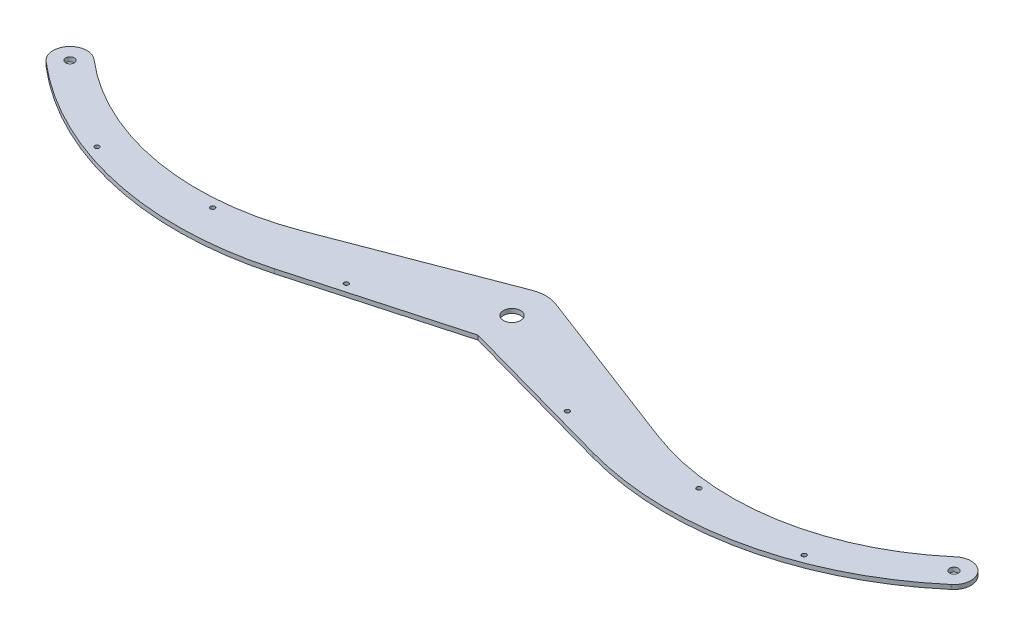
from build123d import *

# Parameters (mm, degrees)
BOSS_EXTRUDE1_DEPTH = 3.18
SKETCH3_R           = 3.175
SKETCH3_R_2         = 6.35
SKETCH3_R_3         = 1.65
CUT_EXTRUDE1_DEPTH  = 4.18


with BuildPart() as part:
    # Sketch1 → Boss-Extrude1 (new body)
    with BuildSketch(Plane(origin=(0, 0, 0), x_dir=(1, 0, 0), z_dir=(0, 1, 0))):
        with BuildLine():
            Line((-316.883271773, 9.506246519), (-316.457354569, 9.142585196))
            ThreePointArc((-316.457354569, 9.142585196), (-227.815789201, -32.465901654), (-130.352994696, -23.000333716))
            Line((-130.352994696, -23.000333716), (-8.915781366, 23.356130729))
            ThreePointArc((-8.915781366, 23.356130729), (0, 25), (8.915781366, 23.356130729))
            Line((8.915781366, 23.356130729), (130.352994696, -23.000333716))
            ThreePointArc((130.352994696, -23.000333716), (227.815789201, -32.465901654), (316.457354569, 9.142585196))
            Line((316.457354569, 9.142585196), (316.883271773, 9.506246519))
            ThreePointArc((316.883271773, 9.506246519), (334.506246519, 8.116728227), (333.116728227, -9.506246519))
            Line((333.116728227, -9.506246519), (332.690811024, -9.869907842))
            ThreePointArc((332.690811024, -9.869907842), (230.873321689, -60.601151934), (117.157638275, -57.567407196))
            Line((117.157638275, -57.567407196), (0, -25))
            Line((0, -25), (-117.157638275, -57.567407196))
            ThreePointArc((-117.157638275, -57.567407196), (-230.873321689, -60.601151934), (-332.690811024, -9.869907842))
            Line((-332.690811024, -9.869907842), (-333.116728227, -9.506246519))
            ThreePointArc((-333.116728227, -9.506246519), (-334.506246519, 8.116728227), (-316.883271773, 9.506246519))
        make_face()
    extrude(amount=BOSS_EXTRUDE1_DEPTH)

    # Sketch3 → Cut-Extrude1 (cut, through all)
    with BuildSketch(Plane(origin=(0, 3.18, 0), x_dir=(1, 0, 0), z_dir=(0, 1, 0))):
        with Locations((-325, 0)):
            Circle(SKETCH3_R)
        Circle(SKETCH3_R_2)
        with Locations((-260, -45.151120288)):
            Circle(SKETCH3_R_3)
        with Locations((-178.75, -41.327805807)):
            Circle(SKETCH3_R_3)
        with Locations((-81.25, -40.58582431)):
            Circle(SKETCH3_R_3)
        with Locations((81.25, -40.58582431)):
            Circle(SKETCH3_R_3)
        with Locations((178.75, -41.327805807)):
            Circle(SKETCH3_R_3)
        with Locations((260, -45.151120288)):
            Circle(SKETCH3_R_3)
        with Locations((325, 0)):
            Circle(SKETCH3_R)
    extrude(amount=-CUT_EXTRUDE1_DEPTH, mode=Mode.SUBTRACT)


solid = part.part
